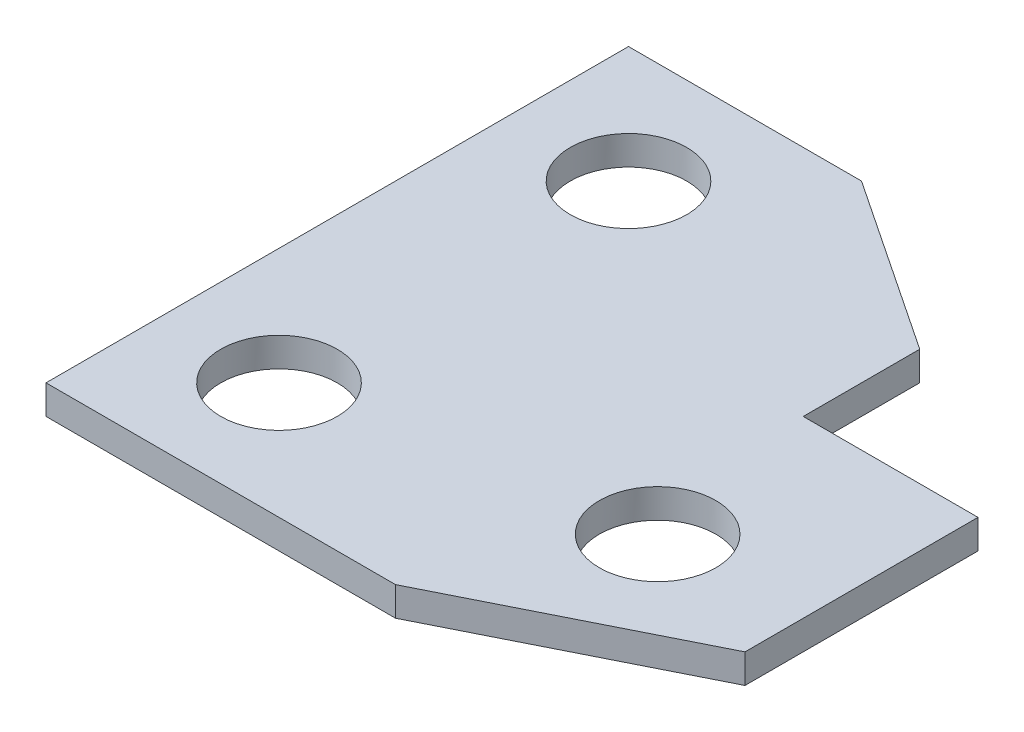
from build123d import *

# Parameters (mm, degrees)
BOSS_EXTRUDE1_DEPTH     = 5
CUT_EXTRUDE6_DEPTH      = 101.357811426
CUT_EXTRUDE6_DEPTH_BACK = 101.357811426
SKETCH1_7_R             = 10


with BuildPart() as part:
    # Sketch1 → Boss-Extrude1 (new body)
    with BuildSketch(Plane(origin=(0, 0, 0), x_dir=(1, 0, 0), z_dir=(0, 1, 0))):
        Polygon((-27.164100119, 31.140563444), (-27.164100119, -68.859436556), (32.835899881, -68.859436556), (72.835899881, -48.859436556), (72.835899881, -8.859436556), (42.835899881, -8.859436556), (42.835899881, 11.140563444), (12.835899881, 31.140563444), align=None)
    extrude(amount=BOSS_EXTRUDE1_DEPTH)

    # Sketch1_7 → Cut-Extrude6 (cut, two sides: drawn at the far end of the back side and taken through both)
    with BuildSketch(Plane(origin=(0, 0, 0), x_dir=(1, 0, 0), z_dir=(0, 1, 0)).offset(-CUT_EXTRUDE6_DEPTH_BACK)):
        with Locations((-7.164100119, 11.140563444)):
            Circle(SKETCH1_7_R)
        with Locations((-7.164100119, -48.859436556)):
            Circle(SKETCH1_7_R)
        with Locations((47.835899881, -38.859436556)):
            Circle(SKETCH1_7_R)
    extrude(amount=CUT_EXTRUDE6_DEPTH + CUT_EXTRUDE6_DEPTH_BACK, mode=Mode.SUBTRACT)


solid = part.part
